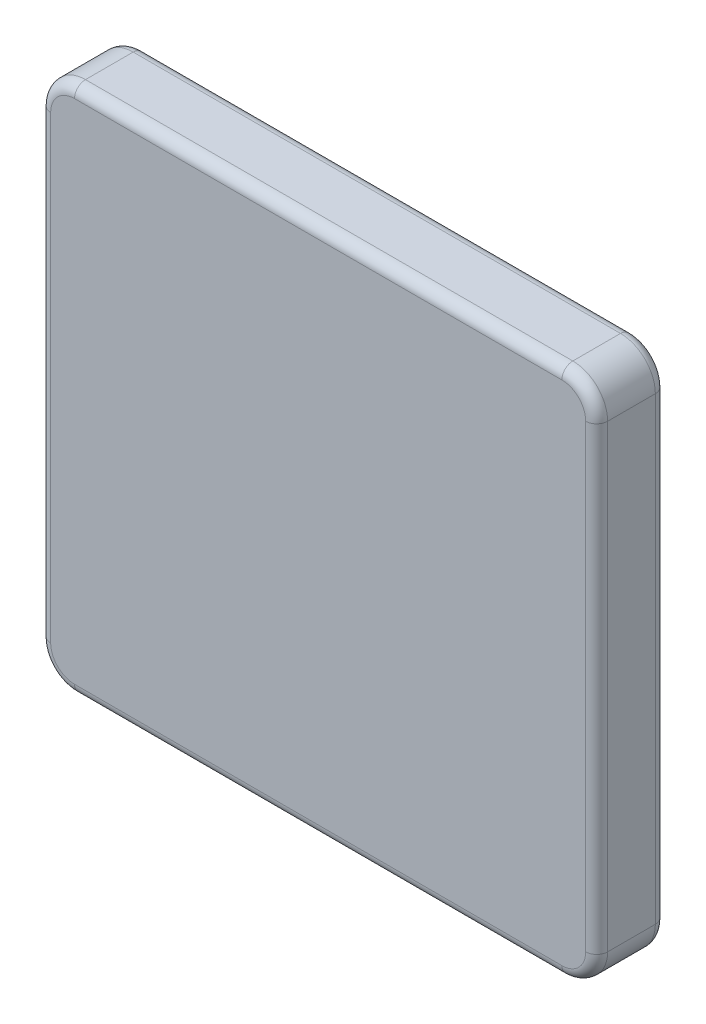
from build123d import *

# Parameters (mm, degrees)
SKETCH1_W           = 2032
SKETCH1_H           = 1930.4
BOSS_EXTRUDE1_DEPTH = 254
FILLET1_R           = 127
FILLET2_R           = 40


with BuildPart() as part:
    # Sketch1 → Boss-Extrude1 (new body)
    with BuildSketch(Plane.XY):
        with Locations((1016, 965.2)):
            Rectangle(SKETCH1_W, SKETCH1_H)
    extrude(amount=BOSS_EXTRUDE1_DEPTH)

    # Fillet1
    fillet1_edges = [part.edges().sort_by_distance(p)[0] for p in [
        (0, 1930.4, 127),
        (2032, 1930.4, 127),
        (2032, 0, 127),
        (0, 0, 127),
    ]]
    fillet(fillet1_edges, radius=FILLET1_R)

    # Fillet2
    fillet2_edges = [part.edges().sort_by_distance(p)[0] for p in [
        (0, 965.2, 0),
        (0, 965.2, 254),
        (1016, 1930.4, 0),
        (2032, 965.2, 0),
        (1016, 0, 0),
        (1994.802561211, 1893.202561211, 0),
        (1994.802561211, 37.197438789, 0),
        (37.197438789, 37.197438789, 0),
        (37.197438789, 1893.202561211, 0),
        (1016, 1930.4, 254),
        (1016, 0, 254),
        (2032, 965.2, 254),
        (1994.802561211, 1893.202561211, 254),
        (1994.802561211, 37.197438789, 254),
        (37.197438789, 37.197438789, 254),
        (37.197438789, 1893.202561211, 254),
    ]]
    fillet(fillet2_edges, radius=FILLET2_R)


solid = part.part
